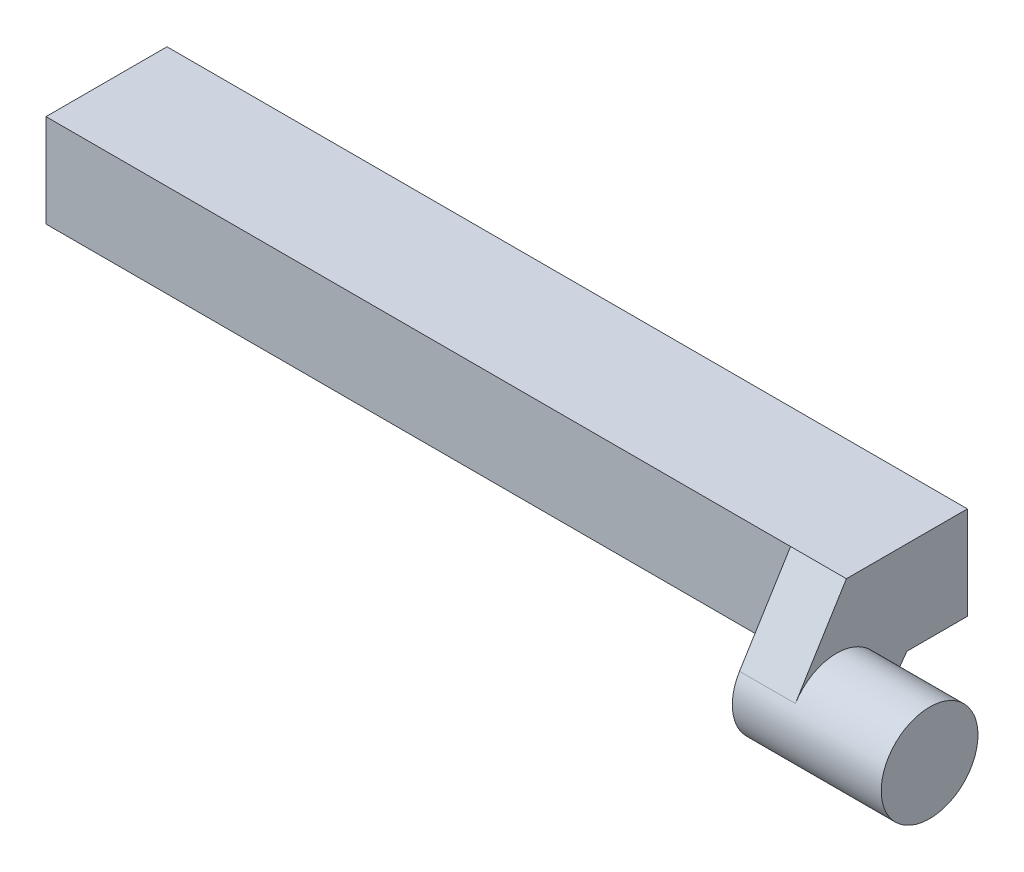
from build123d import *
from build123d.topology import SkipClean

# Parameters (mm, degrees)
SKETCH2_W           = 6.5
SKETCH2_H           = 5
SKETCH2_W_2         = 4.5
SKETCH2_H_2         = 4.5
BOSS_EXTRUDE1_DEPTH = 2
BOSS_EXTRUDE2_START = 2
SKETCH2_2_W         = 6.5
SKETCH2_2_H         = 5
SKETCH2_2_W_2       = 4.5
SKETCH2_2_H_2       = 4.5
BOSS_EXTRUDE2_DEPTH = 38
BOSS_EXTRUDE3_DEPTH = 3
SKETCH6_R           = 2.6
BOSS_EXTRUDE4_DEPTH = 5


with BuildPart() as part:
    # Sketch2 → Boss-Extrude1 (new body)
    with BuildSketch(Plane(origin=(0, 0, 0), x_dir=(0, 0, -1), z_dir=(1, 0, 0))):
        Rectangle(SKETCH2_W, SKETCH2_H)
        Rectangle(SKETCH2_W_2, SKETCH2_H_2, mode=Mode.SUBTRACT)
    extrude(amount=BOSS_EXTRUDE1_DEPTH)

    # Sketch2_2 → Boss-Extrude2 (add)
    with BuildSketch(Plane(origin=(0, 0, 0), x_dir=(0, 0, -1), z_dir=(1, 0, 0)).offset(BOSS_EXTRUDE2_START)):
        Rectangle(SKETCH2_2_W, SKETCH2_2_H)
        Rectangle(SKETCH2_2_W_2, SKETCH2_2_H_2, mode=Mode.SUBTRACT)
        Rectangle(SKETCH2_2_W_2, SKETCH2_2_H_2)
    extrude(amount=BOSS_EXTRUDE2_DEPTH)

    # Sketch5 → Boss-Extrude3 (add)
    with BuildSketch(Plane(origin=(40, 0, 0), x_dir=(0, 0, -1), z_dir=(1, 0, 0))):
        with BuildLine():
            Line((-5.992134655, -1.935858048), (-3.25, 2.5))
            Line((-3.25, 2.5), (3.25, 2.5))
            Line((3.25, 2.5), (3.25, -2.5))
            Line((3.25, -2.5), (0, -2.5))
            Line((0, -2.5), (-1.669999982, -4.821353165))
            ThreePointArc((-1.669999982, -4.821353165), (-5.224212214, -5.465373947), (-5.992134655, -1.935858048))
        make_face()
    extrude(amount=BOSS_EXTRUDE3_DEPTH)

    # Sketch6 → Boss-Extrude4 (add)
    with SkipClean():  # the faces are left unmerged after this step: merging them gives an invalid solid
        with BuildSketch(Plane(origin=(43, 0, 0), x_dir=(0, 0, -1), z_dir=(1, 0, 0))):
            with Locations(Location((-3.780581608, -3.302983909, 0), (0, 0, 148.276697379))):
                Circle(SKETCH6_R)
        extrude(amount=BOSS_EXTRUDE4_DEPTH)


solid = part.part
